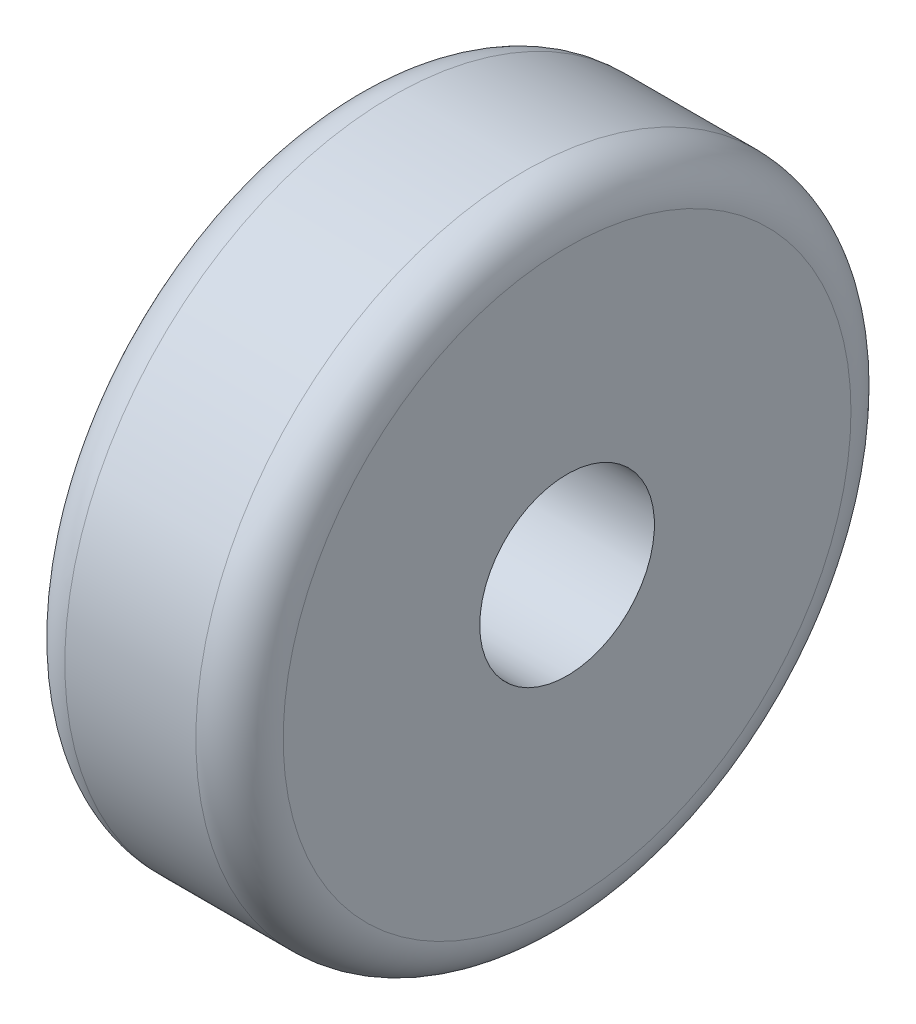
from build123d import *

# Parameters (mm, degrees)
SKETCH1_R           = 150
BOSS_EXTRUDE1_DEPTH = 100
FILLET1_R           = 20
SKETCH2_R           = 40
CUT_EXTRUDE1_DEPTH  = 101


with BuildPart() as part:
    # Sketch1 → Boss-Extrude1 (new body)
    with BuildSketch(Plane(origin=(0, 0, 0), x_dir=(0, 0, -1), z_dir=(1, 0, 0))):
        Circle(SKETCH1_R)
    extrude(amount=BOSS_EXTRUDE1_DEPTH)

    # Fillet1
    fillet1_edges = [part.edges().sort_by_distance(p)[0] for p in [
        (0, 0, 150),
        (100, 0, 150),
    ]]
    fillet(fillet1_edges, radius=FILLET1_R)

    # Sketch2 → Cut-Extrude1 (cut, through all)
    with BuildSketch(Plane.ZY):
        Circle(SKETCH2_R)
    extrude(amount=-CUT_EXTRUDE1_DEPTH, mode=Mode.SUBTRACT)


solid = part.part
